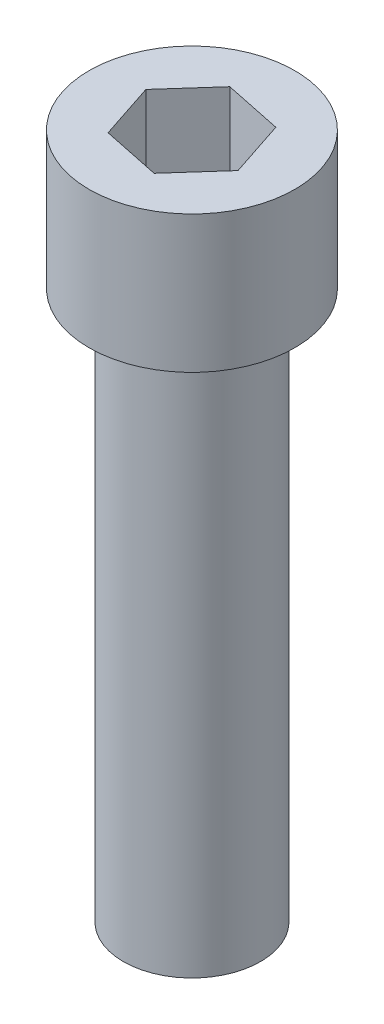
from build123d import *

# Parameters (mm, degrees)
SKETCH1_R           = 3.175
BOSS_EXTRUDE1_DEPTH = 25.4
SKETCH2_R           = 4.7625
BOSS_EXTRUDE2_DEPTH = 6.35
CUT_EXTRUDE1_DEPTH  = 6.35


with BuildPart() as part:
    # Sketch1 → Boss-Extrude1 (new body)
    with BuildSketch(Plane(origin=(0, 0, 0), x_dir=(1, 0, 0), z_dir=(0, 1, 0))):
        Circle(SKETCH1_R)
    extrude(amount=BOSS_EXTRUDE1_DEPTH)

    # Sketch2 → Boss-Extrude2 (add)
    with BuildSketch(Plane(origin=(0, 25.4, 0), x_dir=(1, 0, 0), z_dir=(0, 1, 0))):
        Circle(SKETCH2_R)
    extrude(amount=BOSS_EXTRUDE2_DEPTH)

    # Sketch3 → Cut-Extrude1 (cut)
    with BuildSketch(Plane(origin=(0, 31.75, 0), x_dir=(1, 0, 0), z_dir=(0, 1, 0))):
        Polygon((-2.692012499, 0.559944154), (-1.830932112, -2.051379134), (0.861080387, -2.611323288), (2.692012499, -0.559944154), (1.830932112, 2.051379134), (-0.861080387, 2.611323288), align=None)
    extrude(amount=-CUT_EXTRUDE1_DEPTH, mode=Mode.SUBTRACT)


solid = part.part
